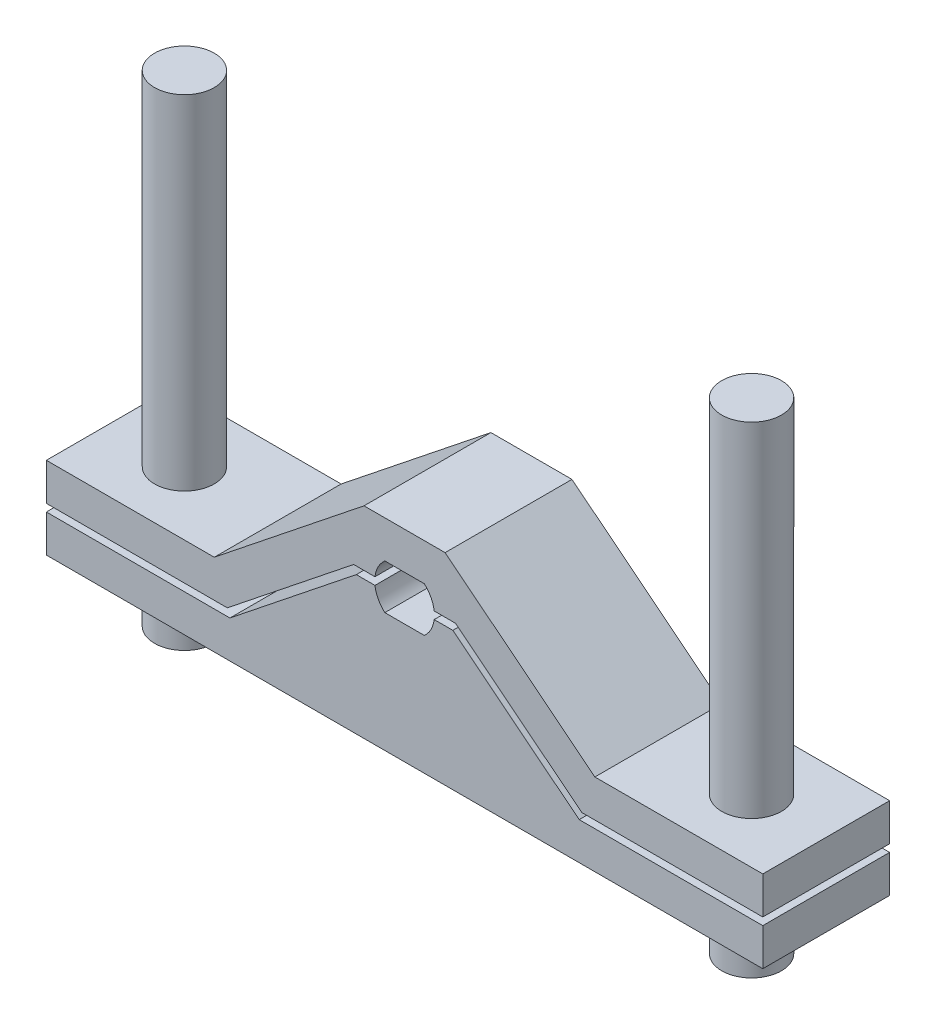
from build123d import *

# Parameters (mm, degrees)
EXTRUDE_1_DEPTH      = 34
EXTRUDE_1_2_DEPTH    = 34
SKETCH_3_R           = 8
EXTRUDE_2_DEPTH      = 92
EXTRUDE_2_DEPTH_BACK = 37
SKETCH_4_R           = 8.5
CUT_EXTRUDE_1_DEPTH  = 10


with BuildPart() as part:
    # Эскиз2 → Бобышка-Вытянуть1 (new body)
    with BuildSketch(Plane.XY):
        with BuildLine():
            Line((-5.291502622, 6), (0, 6))
            Line((0, 6), (0, 16))
            Line((0, 16), (-10.864298335, 16))
            Line((-10.864298335, 16), (-51, -16))
            Line((-51, -16), (-96, -16))
            Line((-96, -16), (-96, -26))
            Line((-96, -26), (-47.501460178, -26))
            Line((-47.501460178, -26), (-13.636961898, 1))
            Line((-13.636961898, 1), (-7.937253933, 1))
            ThreePointArc((-7.937253933, 1), (-7.071067812, 3.741657387), (-5.291502622, 6))
        make_face()
    extrude(amount=-EXTRUDE_1_DEPTH)

    # Эскиз3 → Бобышка-Вытянуть2 (add, two sides)
    with BuildSketch(Plane(origin=(0, -16, 0), x_dir=(1, 0, 0), z_dir=(0, 1, 0))) as extrude_2_sk:
        with Locations((-76, 17)):
            Circle(SKETCH_3_R)
    extrude(amount=EXTRUDE_2_DEPTH)
    extrude(extrude_2_sk.sketch, amount=-EXTRUDE_2_DEPTH_BACK)

    # Mirror 1 2: part across plane


with BuildPart() as body_2:
    # Эскиз2 → Extrude 1 2 (new body)
    with BuildSketch(Plane.XY):
        with BuildLine():
            Line((0, -6), (-5.291502622, -6))
            ThreePointArc((-5.291502622, -6), (-7.071067812, -3.741657387), (-7.937253933, -1))
            Line((-7.937253933, -1), (-12.937253933, -1))
            Line((-12.937253933, -1), (-46.801752213, -28))
            Line((-46.801752213, -28), (-96, -28))
            Line((-96, -28), (-96, -38))
            Line((-96, -38), (0, -38))
            Line((0, -38), (0, -6))
        make_face()
    extrude(amount=-EXTRUDE_1_2_DEPTH)

    # Эскиз4 → Вырез-Вытянуть1 (cut)
    with BuildSketch(Plane.XZ.offset(38)):
        with Locations((-76, -17)):
            Circle(SKETCH_4_R)
    extrude(amount=-CUT_EXTRUDE_1_DEPTH, mode=Mode.SUBTRACT)

    # Зеркальное отражение1: body 2 across plane


with BuildPart() as body_2_1:
    add(body_2.part)
    add(body_2.part.mirror(Plane(origin=(0, -6, -138.785495179), x_dir=(0, 0, 1), z_dir=(1, 0, 0))))


with BuildPart() as part_1:
    add(part.part)
    add(part.part.mirror(Plane(origin=(0, -6, -138.785495179), x_dir=(0, 0, 1), z_dir=(1, 0, 0))))


solid = Compound([body_2_1.part, part_1.part])
